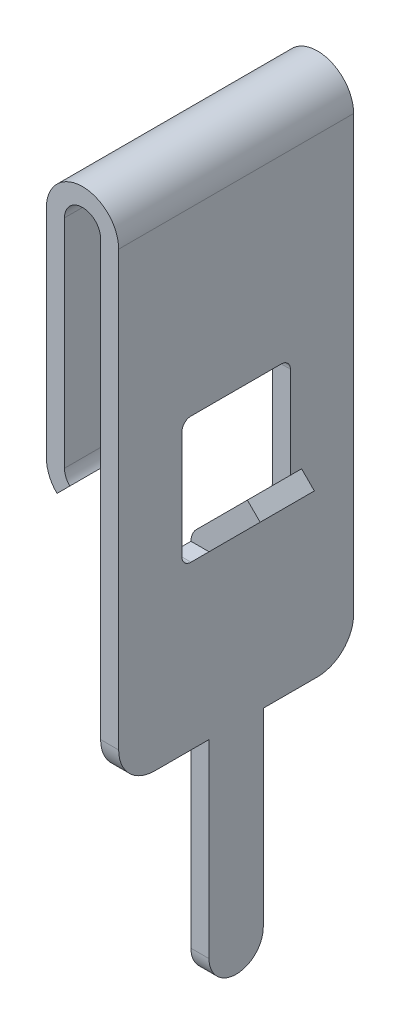
from build123d import *

# Parameters (mm, degrees)
EXTRUDE_1_DEPTH     = 6.5
CUT_EXTRUDE_1_DEPTH = 2
SKETCH_3_W          = 2
SKETCH_3_H          = 2
CUT_EXTRUDE_2_DEPTH = 2.5
SKETCH_4_W          = 2
SKETCH_4_H          = 2
CUT_EXTRUDE_3_DEPTH = 2.5
CUT_EXTRUDE_4_DEPTH = 0.6
SKETCH_6_W          = 1.5
SKETCH_6_H          = 0.707106781
EXTRUDE_2_DEPTH     = 0.5
CUT_EXTRUDE_5_DEPTH = 2
FILLET_1_R          = 0.5


with BuildPart() as part:
    # Эскиз1 → Бобышка-Вытянуть1 (new body)
    with BuildSketch(Plane.XY):
        with BuildLine():
            Line((-2, 19), (-2, 13))
            ThreePointArc((-2, 13), (-1.923879533, 12.617316568), (-1.707106781, 12.292893219))
            Line((-1.707106781, 12.292893219), (-1.353553391, 12.646446609))
            ThreePointArc((-1.353553391, 12.646446609), (-1.461939766, 12.808658284), (-1.5, 13))
            Line((-1.5, 13), (-1.5, 19))
            ThreePointArc((-1.5, 19), (-1, 19.5), (-0.5, 19))
            Line((-0.5, 19), (-0.5, 0))
            Line((-0.5, 0), (0, 0))
            Line((0, 0), (0, 10.5))
            Line((0, 10.5), (1.414213562, 11.914213562))
            Line((1.414213562, 11.914213562), (1.060660172, 12.267766953))
            Line((1.060660172, 12.267766953), (0, 11.207106781))
            Line((0, 11.207106781), (0, 19))
            ThreePointArc((0, 19), (-1, 20), (-2, 19))
        make_face()
    extrude(amount=EXTRUDE_1_DEPTH)

    # Эскиз2 → Вырез-Вытянуть1 (cut)
    with BuildSketch(Plane.ZY.offset(0.5)):
        with BuildLine():
            Line((4, 6), (5.5, 6))
            ThreePointArc((5.5, 6), (6.207106781, 6.292893219), (6.5, 7))
            Line((6.5, 7), (8.5, 7))
            Line((8.5, 7), (8.5, -1))
            Line((8.5, -1), (-2, -1))
            Line((-2, -1), (-2, 7))
            Line((-2, 7), (0, 7))
            ThreePointArc((0, 7), (0.292893219, 6.292893219), (1, 6))
            Line((1, 6), (2.5, 6))
            Line((2.5, 6), (2.5, 0.75))
            ThreePointArc((2.5, 0.75), (3.25, 0), (4, 0.75))
            Line((4, 0.75), (4, 6))
        make_face()
    extrude(amount=-CUT_EXTRUDE_1_DEPTH, mode=Mode.SUBTRACT)

    # Эскиз3 → Вырез-Вытянуть2 (cut)
    with BuildSketch(Plane.XY.offset(6.5)):
        with Locations((1, 11.5)):
            Rectangle(SKETCH_3_W, SKETCH_3_H)
    extrude(amount=-CUT_EXTRUDE_2_DEPTH, mode=Mode.SUBTRACT)

    # Эскиз4 → Вырез-Вытянуть3 (cut)
    with BuildSketch(Plane(origin=(0, 0, 0), x_dir=(-1, 0, 0), z_dir=(0, 0, -1))):
        with Locations((-1, 11.5)):
            Rectangle(SKETCH_4_W, SKETCH_4_H)
    extrude(amount=-CUT_EXTRUDE_3_DEPTH, mode=Mode.SUBTRACT)

    # Эскиз5 → Вырез-Вытянуть4 (cut)
    with BuildSketch(Plane(origin=(0, 0, 0), x_dir=(0, 0, -1), z_dir=(1, 0, 0))):
        with BuildLine():
            Line((-3.25, 10.5), (-2, 10.5))
            ThreePointArc((-2, 10.5), (-1.823223305, 10.573223305), (-1.75, 10.75))
            Line((-1.75, 10.75), (-1.75, 13.75))
            ThreePointArc((-1.75, 13.75), (-1.823223305, 13.926776695), (-2, 14))
            Line((-2, 14), (-4.5, 14))
            ThreePointArc((-4.5, 14), (-4.676776695, 13.926776695), (-4.75, 13.75))
            Line((-4.75, 13.75), (-4.75, 10.75))
            ThreePointArc((-4.75, 10.75), (-4.676776695, 10.573223305), (-4.5, 10.5))
            Line((-4.5, 10.5), (-3.25, 10.5))
        make_face()
    extrude(amount=-CUT_EXTRUDE_4_DEPTH, mode=Mode.SUBTRACT)

    # Эскиз6 → Бобышка-Вытянуть2 (add)
    with BuildSketch(Plane.ZY):
        with Locations((3.25, 10.853553391)):
            Rectangle(SKETCH_6_W, SKETCH_6_H)
    extrude(amount=EXTRUDE_2_DEPTH)

    # Эскиз7 → Вырез-Вытянуть5 (cut)
    with BuildSketch(Plane(origin=(0, 0, 2.5), x_dir=(-1, 0, 0), z_dir=(0, 0, -1))):
        Polygon((0, 11.207106781), (0.5, 10.707106781), (1, 10.707106781), (1, 11.207106781), align=None)
    extrude(amount=-CUT_EXTRUDE_5_DEPTH, mode=Mode.SUBTRACT)

    # Скругление1
    fillet_1_edges = [part.edges().sort_by_distance(p)[0] for p in [
        (-0.5, 10.707106781, 3.25),
    ]]
    fillet(fillet_1_edges, radius=FILLET_1_R)


solid = part.part
